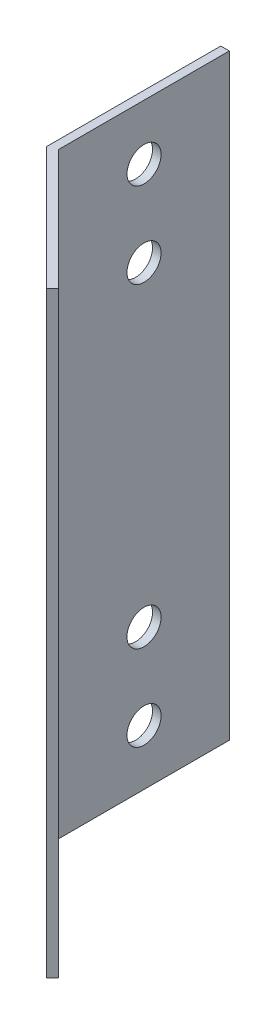
from build123d import *

# Parameters (mm, degrees)
EXTRUSION1_DEPTH = 70
EXTRUSION2_REACH = 3
ESQUISSE2_R      = 2
EXTRUSION3_REACH = 13.207
ESQUISSE3_R      = 2


with BuildPart() as part:
    # Esquisse1 → Extrusion1 (new body)
    with BuildSketch(Plane(origin=(0, 0, 0), x_dir=(1, 0, 0), z_dir=(0, 1, 0))):
        Polygon((0, 0), (0, 20.414213562), (1, 20.414213562), (1, 0.414213562), (15.142135624, -13.727922061), (14.435028843, -14.435028843), align=None)
    extrude(amount=EXTRUSION1_DEPTH)

    # Esquisse2 → Extrusion2 (cut, up to next)
    with BuildSketch(Plane(origin=(1, 0, 0), x_dir=(0, 0, -1), z_dir=(1, 0, 0)), mode=Mode.PRIVATE) as extrusion2_sk1:
        with Locations((10.414213562, 16.5)):
            Circle(ESQUISSE2_R)
    extrusion2_tool1 = extrude(extrusion2_sk1.sketch, amount=-EXTRUSION2_REACH, mode=Mode.PRIVATE) & part.part
    add(extrusion2_tool1.solids().sort_by_distance((1, 16.5, -10.414214))[0], mode=Mode.SUBTRACT)
    # Esquisse2 → Extrusion2 (cut, up to next)
    with BuildSketch(Plane(origin=(1, 0, 0), x_dir=(0, 0, -1), z_dir=(1, 0, 0)), mode=Mode.PRIVATE) as extrusion2_sk2:
        with Locations((10.414213562, 6.5)):
            Circle(ESQUISSE2_R)
    extrusion2_tool2 = extrude(extrusion2_sk2.sketch, amount=-EXTRUSION2_REACH, mode=Mode.PRIVATE) & part.part
    add(extrusion2_tool2.solids().sort_by_distance((1, 6.5, -10.414214))[0], mode=Mode.SUBTRACT)
    # Esquisse2 → Extrusion2 (cut, up to next)
    with BuildSketch(Plane(origin=(1, 0, 0), x_dir=(0, 0, -1), z_dir=(1, 0, 0)), mode=Mode.PRIVATE) as extrusion2_sk3:
        with Locations((10.414213562, 53.5)):
            Circle(ESQUISSE2_R)
    extrusion2_tool3 = extrude(extrusion2_sk3.sketch, amount=-EXTRUSION2_REACH, mode=Mode.PRIVATE) & part.part
    add(extrusion2_tool3.solids().sort_by_distance((1, 53.5, -10.414214))[0], mode=Mode.SUBTRACT)
    # Esquisse2 → Extrusion2 (cut, up to next)
    with BuildSketch(Plane(origin=(1, 0, 0), x_dir=(0, 0, -1), z_dir=(1, 0, 0)), mode=Mode.PRIVATE) as extrusion2_sk4:
        with Locations((10.414213562, 63.5)):
            Circle(ESQUISSE2_R)
    extrusion2_tool4 = extrude(extrusion2_sk4.sketch, amount=-EXTRUSION2_REACH, mode=Mode.PRIVATE) & part.part
    add(extrusion2_tool4.solids().sort_by_distance((1, 63.5, -10.414214))[0], mode=Mode.SUBTRACT)

    # Esquisse3 → Extrusion3 (cut, up to next)
    with BuildSketch(Plane(origin=(0.707106781, 0, -0.707106781), x_dir=(-0.707106781, 0, -0.707106781), z_dir=(0.707106781, 0, -0.707106781)), mode=Mode.PRIVATE) as extrusion3_sk1:
        with Locations((-10.414213562, 53.5)):
            Circle(ESQUISSE3_R)
    extrusion3_tool1 = extrude(extrusion3_sk1.sketch, amount=-EXTRUSION3_REACH, mode=Mode.PRIVATE) & part.part
    add(extrusion3_tool1.solids().sort_by_distance((8.071068, 53.5, 6.656854))[0], mode=Mode.SUBTRACT)
    # Esquisse3 → Extrusion3 (cut, up to next)
    with BuildSketch(Plane(origin=(0.707106781, 0, -0.707106781), x_dir=(-0.707106781, 0, -0.707106781), z_dir=(0.707106781, 0, -0.707106781)), mode=Mode.PRIVATE) as extrusion3_sk2:
        with Locations((-10.414213562, 63.5)):
            Circle(ESQUISSE3_R)
    extrusion3_tool2 = extrude(extrusion3_sk2.sketch, amount=-EXTRUSION3_REACH, mode=Mode.PRIVATE) & part.part
    add(extrusion3_tool2.solids().sort_by_distance((8.071068, 63.5, 6.656854))[0], mode=Mode.SUBTRACT)
    # Esquisse3 → Extrusion3 (cut, up to next)
    with BuildSketch(Plane(origin=(0.707106781, 0, -0.707106781), x_dir=(-0.707106781, 0, -0.707106781), z_dir=(0.707106781, 0, -0.707106781)), mode=Mode.PRIVATE) as extrusion3_sk3:
        with Locations((-10.414213562, 6.5)):
            Circle(ESQUISSE3_R)
    extrusion3_tool3 = extrude(extrusion3_sk3.sketch, amount=-EXTRUSION3_REACH, mode=Mode.PRIVATE) & part.part
    add(extrusion3_tool3.solids().sort_by_distance((8.071068, 6.5, 6.656854))[0], mode=Mode.SUBTRACT)
    # Esquisse3 → Extrusion3 (cut, up to next)
    with BuildSketch(Plane(origin=(0.707106781, 0, -0.707106781), x_dir=(-0.707106781, 0, -0.707106781), z_dir=(0.707106781, 0, -0.707106781)), mode=Mode.PRIVATE) as extrusion3_sk4:
        with Locations((-10.414213562, 16.5)):
            Circle(ESQUISSE3_R)
    extrusion3_tool4 = extrude(extrusion3_sk4.sketch, amount=-EXTRUSION3_REACH, mode=Mode.PRIVATE) & part.part
    add(extrusion3_tool4.solids().sort_by_distance((8.071068, 16.5, 6.656854))[0], mode=Mode.SUBTRACT)


solid = part.part
